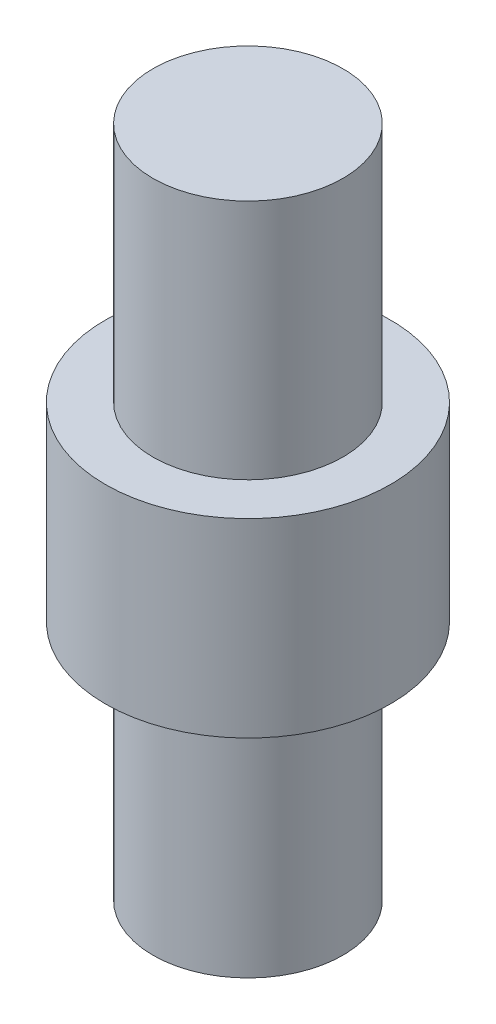
from build123d import *

# Parameters (mm, degrees)
SKETCH1_R           = 1.5
BOSS_EXTRUDE1_DEPTH = 1
SKETCH2_R           = 1
BOSS_EXTRUDE2_DEPTH = 2.54


with BuildPart() as part:
    # Sketch1 → Boss-Extrude1 (new body, symmetric)
    with BuildSketch(Plane(origin=(0, 0, 0), x_dir=(1, 0, 0), z_dir=(0, 1, 0))):
        Circle(SKETCH1_R)
    extrude(amount=BOSS_EXTRUDE1_DEPTH, both=True)

    # Sketch2 → Boss-Extrude2 (add)
    with BuildSketch(Plane(origin=(0, 1, 0), x_dir=(1, 0, 0), z_dir=(0, 1, 0))):
        Circle(SKETCH2_R)
    boss_extrude2 = extrude(amount=BOSS_EXTRUDE2_DEPTH)

    # Mirror1: Boss-Extrude2 across plane
    add(boss_extrude2.mirror(Plane.ZX))


solid = part.part
